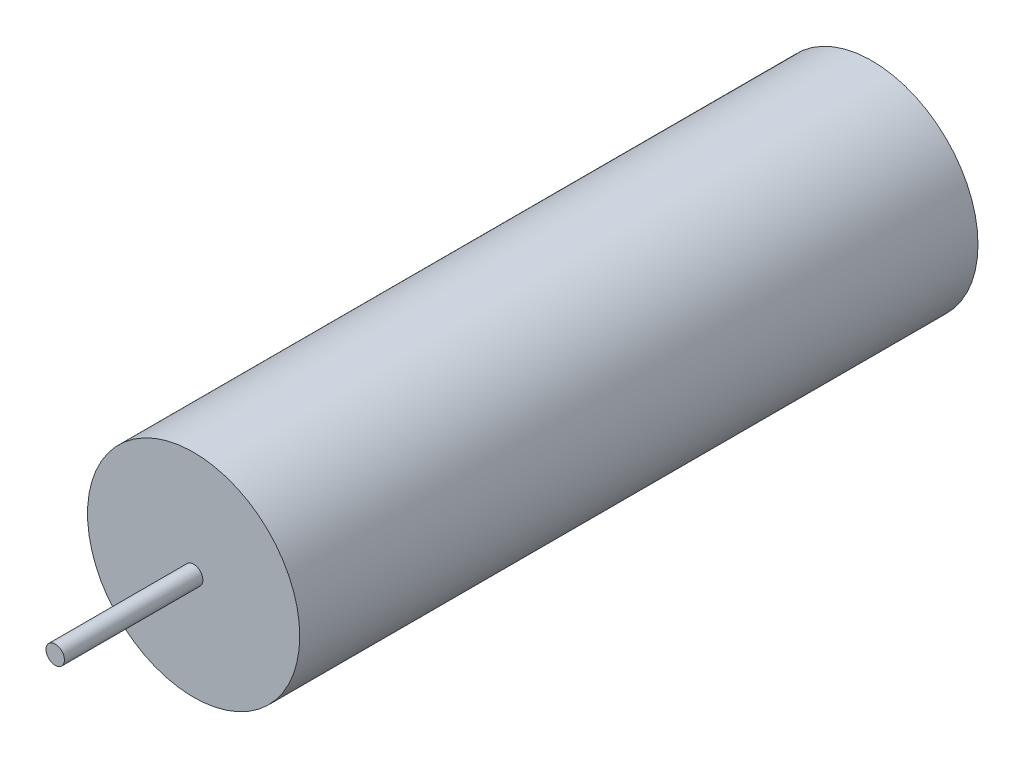
from build123d import *

# Parameters (mm, degrees)
SKETCH1_R           = 2.921
BOSS_EXTRUDE1_DEPTH = 18.669
SKETCH2_R           = 0.254
BOSS_EXTRUDE2_DEPTH = 3.81


with BuildPart() as part:
    # Sketch1 → Boss-Extrude1 (new body)
    with BuildSketch(Plane.XY):
        Circle(SKETCH1_R)
    extrude(amount=BOSS_EXTRUDE1_DEPTH)

    # Sketch2 → Boss-Extrude2 (add)
    with BuildSketch(Plane.XY.offset(18.669)):
        Circle(SKETCH2_R)
    extrude(amount=BOSS_EXTRUDE2_DEPTH)


solid = part.part
